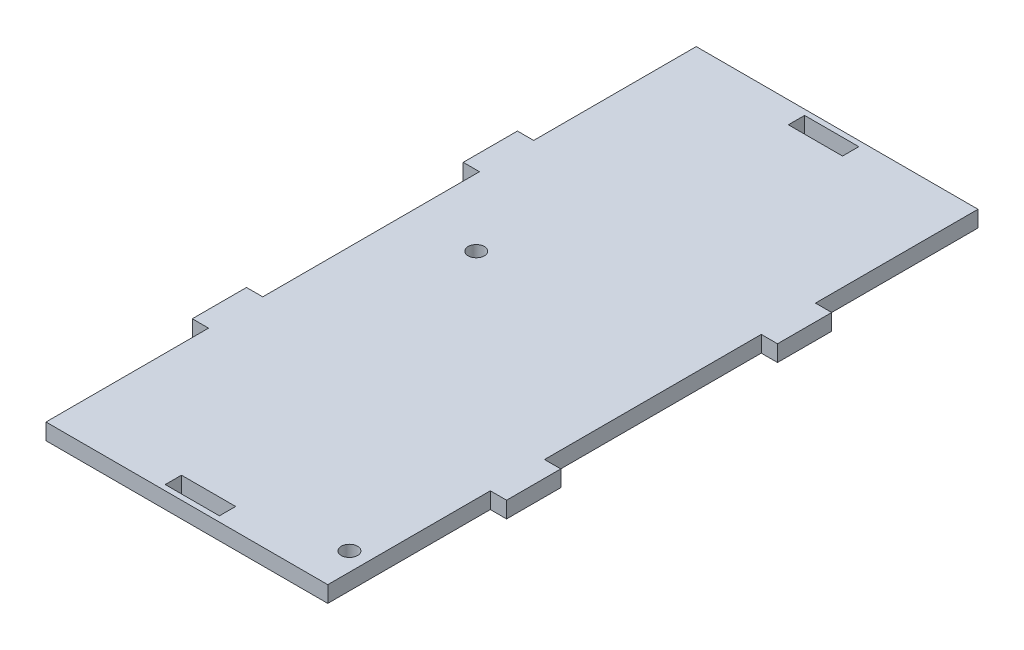
from build123d import *

# Parameters (mm, degrees)
SKETCH1_R           = 1.5
SKETCH1_W           = 10
SKETCH1_H           = 3
BOSS_EXTRUDE1_DEPTH = 3


with BuildPart() as part:
    # Sketch1 → Boss-Extrude1 (new body)
    with BuildSketch(Plane(origin=(0, 0, 0), x_dir=(1, 0, 0), z_dir=(0, 1, 0))):
        Polygon((-26, -30), (-26, -60), (26, -60), (26, -30), (29, -30), (29, -20), (26, -20), (26, 20), (29, 20), (29, 30), (26, 30), (26, 60), (-26, 60), (-26, 30), (-29, 30), (-29, 20), (-26, 20), (-26, -20), (-29, -20), (-29, -30), align=None)
        with Locations((22.6, -52.6)):
            Circle(SKETCH1_R, mode=Mode.SUBTRACT)
        with Locations((-13.6, 7)):
            Circle(SKETCH1_R, mode=Mode.SUBTRACT)
        with Locations((0, -57.5)):
            Rectangle(SKETCH1_W, SKETCH1_H, mode=Mode.SUBTRACT)
        with Locations((0, 57.5)):
            Rectangle(SKETCH1_W, SKETCH1_H, mode=Mode.SUBTRACT)
    extrude(amount=BOSS_EXTRUDE1_DEPTH)


solid = part.part
